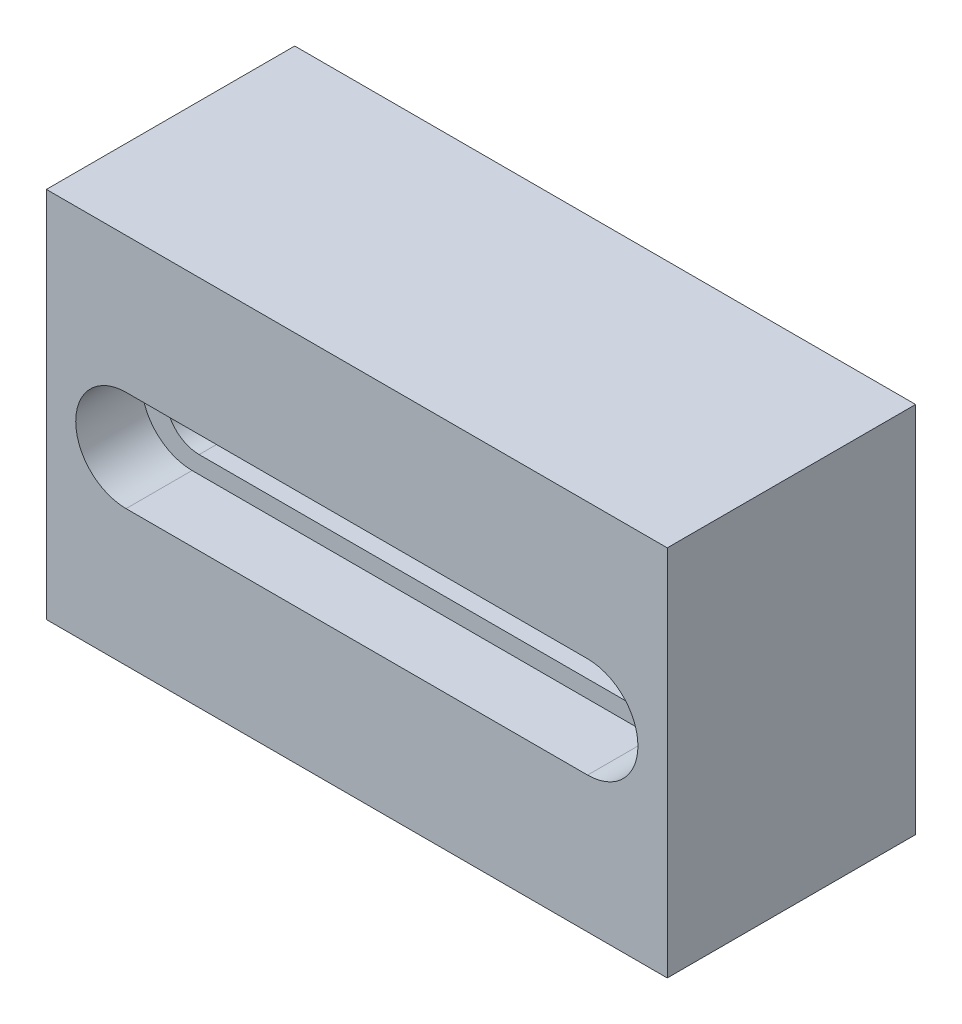
from build123d import *

# Parameters (mm, degrees)
SKETCH1_W           = 127
SKETCH1_H           = 50.8
BOSS_EXTRUDE1_DEPTH = 76.2
SKETCH2_R           = 6.75
CUT_EXTRUDE5_DEPTH  = 51.8
SKETCH3_R           = 10.3
CUT_EXTRUDE6_DEPTH  = 13.5


with BuildPart() as part:
    # Sketch1 → Boss-Extrude1 (new body)
    with BuildSketch(Plane(origin=(0, 0, 0), x_dir=(1, 0, 0), z_dir=(0, 1, 0))):
        with Locations((63.5, 25.4)):
            Rectangle(SKETCH1_W, SKETCH1_H)
    extrude(amount=BOSS_EXTRUDE1_DEPTH)

    # Sketch2 → Cut-Extrude5 (cut, through all)
    with BuildSketch(Plane.XY):
        with BuildLine():
            Line((63.5, 38.1), (63.5, 31.35))
            Line((63.5, 31.35), (109.25, 31.35))
            ThreePointArc((109.25, 31.35), (102.5, 38.1), (109.25, 44.85))
            Line((109.25, 44.85), (17.75, 44.85))
            ThreePointArc((17.75, 44.85), (22.522970773, 42.872970773), (24.5, 38.1))
            Line((24.5, 38.1), (63.5, 38.1))
        make_face()
        with BuildLine():
            Line((17.75, 31.35), (63.5, 31.35))
            Line((63.5, 31.35), (63.5, 38.1))
            Line((63.5, 38.1), (24.5, 38.1))
            ThreePointArc((24.5, 38.1), (22.522970773, 33.327029227), (17.75, 31.35))
        make_face()
        with Locations((109.25, 38.1)):
            Circle(SKETCH2_R)
        with BuildLine():
            ThreePointArc((17.75, 44.85), (12.977029227, 42.872970773), (11, 38.1))
            Line((11, 38.1), (24.5, 38.1))
            ThreePointArc((24.5, 38.1), (22.522970773, 42.872970773), (17.75, 44.85))
        make_face()
        with BuildLine():
            Line((24.5, 38.1), (11, 38.1))
            ThreePointArc((11, 38.1), (12.977029227, 33.327029227), (17.75, 31.35))
            ThreePointArc((17.75, 31.35), (22.522970773, 33.327029227), (24.5, 38.1))
        make_face()
    extrude(amount=-CUT_EXTRUDE5_DEPTH, mode=Mode.SUBTRACT)

    # Sketch3 → Cut-Extrude6 (cut)
    with BuildSketch(Plane.XY):
        with BuildLine():
            Line((63.5, 38.1), (63.5, 27.8))
            Line((63.5, 27.8), (110.7, 27.8))
            ThreePointArc((110.7, 27.8), (100.4, 38.099999965), (110.699999929, 48.4))
            Line((110.699999929, 48.4), (16.300000257, 48.4))
            ThreePointArc((16.300000257, 48.4), (23.583199937, 45.383199756), (26.6, 38.1))
            Line((26.6, 38.1), (63.5, 38.1))
        make_face()
        with BuildLine():
            Line((16.3, 27.8), (63.5, 27.8))
            Line((63.5, 27.8), (63.5, 38.1))
            Line((63.5, 38.1), (26.6, 38.1))
            ThreePointArc((26.6, 38.1), (23.583199846, 30.816800154), (16.3, 27.8))
        make_face()
        with BuildLine():
            ThreePointArc((16.300000257, 48.4), (9.016800244, 45.383199937), (6, 38.1))
            Line((6, 38.1), (26.6, 38.1))
            ThreePointArc((26.6, 38.1), (23.583199937, 45.383199756), (16.300000257, 48.4))
        make_face()
        with BuildLine():
            Line((26.6, 38.1), (6, 38.1))
            ThreePointArc((6, 38.1), (9.016800154, 30.816800154), (16.3, 27.8))
            ThreePointArc((16.3, 27.8), (23.583199846, 30.816800154), (26.6, 38.1))
        make_face()
        with Locations((110.7, 38.1)):
            Circle(SKETCH3_R)
    extrude(amount=-CUT_EXTRUDE6_DEPTH, mode=Mode.SUBTRACT)


solid = part.part
